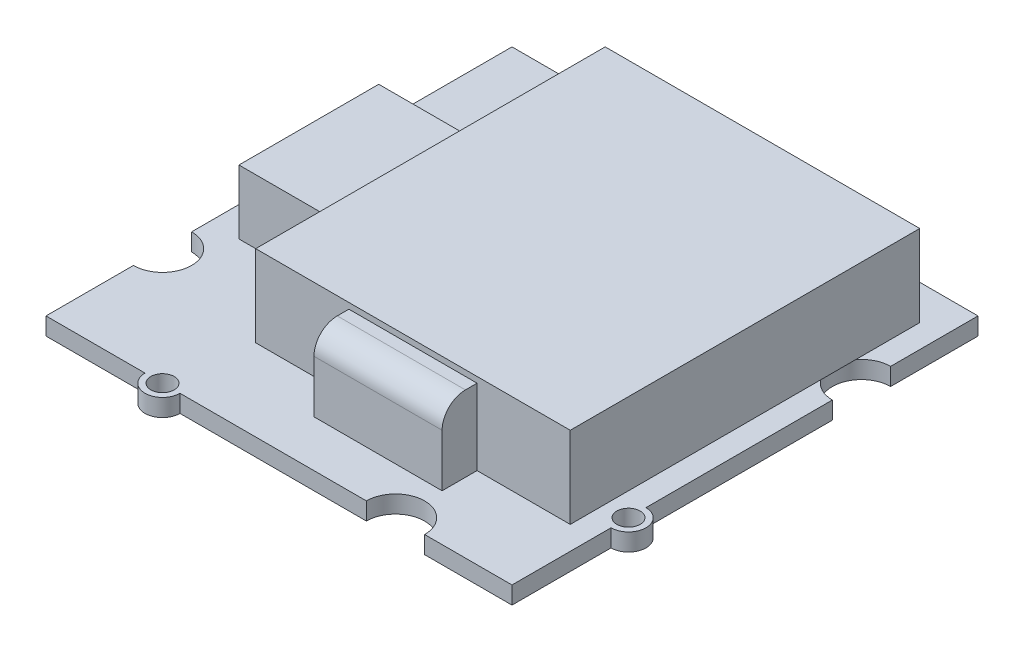
from build123d import *

# Parameters (mm, degrees)
SKETCH1_W           = 40
SKETCH1_H           = 40
BOSS_EXTRUDE1_DEPTH = 1.5
SKETCH2_R           = 1.5
BOSS_EXTRUDE2_DEPTH = 1.5
SKETCH3_R           = 1
SKETCH3_R_2         = 2.5
CUT_EXTRUDE1_DEPTH  = 1.5
SKETCH4_W           = 8
SKETCH4_H           = 12
BOSS_EXTRUDE3_DEPTH = 5.5
SKETCH5_W           = 27
SKETCH5_H           = 30
BOSS_EXTRUDE4_DEPTH = 7
SKETCH6_W           = 11
SKETCH6_H           = 3
BOSS_EXTRUDE5_DEPTH = 6.5
FILLET1_R           = 2


with BuildPart() as part:
    # Sketch1 → Boss-Extrude1 (new body)
    with BuildSketch(Plane(origin=(0, 0, 0), x_dir=(1, 0, 0), z_dir=(0, 1, 0))):
        Rectangle(SKETCH1_W, SKETCH1_H)
    extrude(amount=BOSS_EXTRUDE1_DEPTH)

    # Sketch2 → Boss-Extrude2 (add)
    with BuildSketch(Plane(origin=(0, 1.5, 0), x_dir=(1, 0, 0), z_dir=(0, 1, 0))):
        with Locations((-20, 10)):
            Circle(SKETCH2_R)
        with Locations((10, 20)):
            Circle(SKETCH2_R)
        with Locations((20, -10)):
            Circle(SKETCH2_R)
        with Locations((-10, -20)):
            Circle(SKETCH2_R)
    extrude(amount=-BOSS_EXTRUDE2_DEPTH)

    # Sketch3 → Cut-Extrude1 (cut)
    with BuildSketch(Plane(origin=(0, 1.5, 0), x_dir=(1, 0, 0), z_dir=(0, 1, 0))):
        with Locations((-20, 10)):
            Circle(SKETCH3_R)
        with Locations((10, 20)):
            Circle(SKETCH3_R)
        with Locations((20, -10)):
            Circle(SKETCH3_R)
        with Locations((-10, -20)):
            Circle(SKETCH3_R)
        with Locations((-10, 20)):
            Circle(SKETCH3_R_2)
        with Locations((20, 10)):
            Circle(SKETCH3_R_2)
        with Locations((10, -20)):
            Circle(SKETCH3_R_2)
        with Locations((-20, -10)):
            Circle(SKETCH3_R_2)
    extrude(amount=-CUT_EXTRUDE1_DEPTH, mode=Mode.SUBTRACT)

    # Sketch4 → Boss-Extrude3 (add)
    with BuildSketch(Plane(origin=(0, 1.5, 0), x_dir=(1, 0, 0), z_dir=(0, 1, 0))):
        with Locations((-13.43888983, 0)):
            Rectangle(SKETCH4_W, SKETCH4_H)
    extrude(amount=BOSS_EXTRUDE3_DEPTH)

    # Sketch5 → Boss-Extrude4 (add)
    with BuildSketch(Plane(origin=(0, 1.5, 0), x_dir=(1, 0, 0), z_dir=(0, 1, 0))):
        with Locations((4.5, 2)):
            Rectangle(SKETCH5_W, SKETCH5_H)
    extrude(amount=BOSS_EXTRUDE4_DEPTH)

    # Sketch6 → Boss-Extrude5 (add)
    with BuildSketch(Plane(origin=(0, 1.5, 0), x_dir=(1, 0, 0), z_dir=(0, 1, 0))):
        with Locations((4.5, -14.5)):
            Rectangle(SKETCH6_W, SKETCH6_H)
    extrude(amount=BOSS_EXTRUDE5_DEPTH)

    # Fillet1
    fillet1_edges = [part.edges().sort_by_distance(p)[0] for p in [
        (4.5, 8, 16),
    ]]
    fillet(fillet1_edges, radius=FILLET1_R)


solid = part.part
